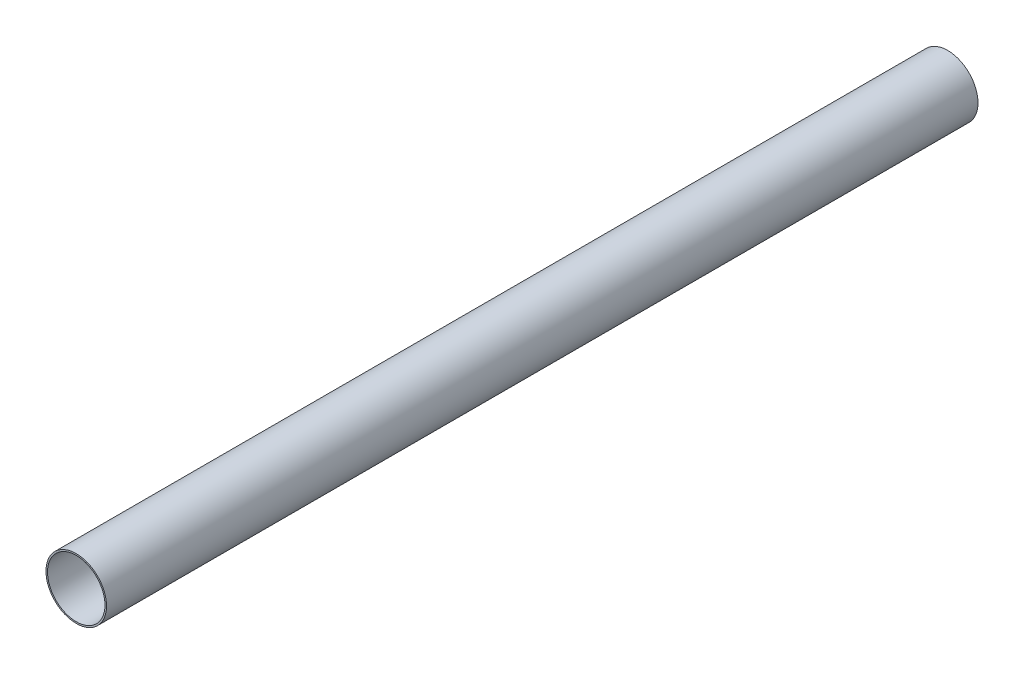
from build123d import *

# Parameters (mm, degrees)
SKETCH1_R           = 52.07
SKETCH1_R_2         = 49.403
BOSS_EXTRUDE1_DEPTH = 1498.6


with BuildPart() as part:
    # Sketch1 → Boss-Extrude1 (new body)
    with BuildSketch(Plane.XY):
        Circle(SKETCH1_R)
        Circle(SKETCH1_R_2, mode=Mode.SUBTRACT)
    extrude(amount=BOSS_EXTRUDE1_DEPTH)


solid = part.part
